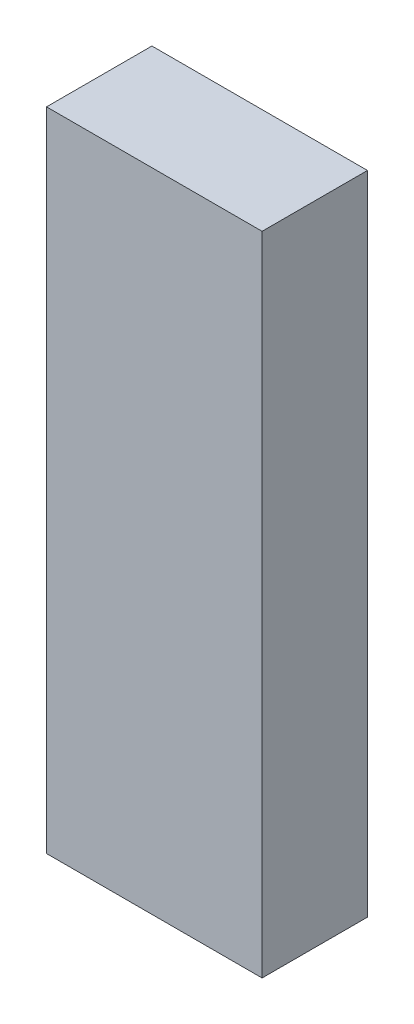
from build123d import *

# Parameters (mm, degrees)
SKETCH1_W           = 45
SKETCH1_H           = 22
BOSS_EXTRUDE1_DEPTH = 67.5


with BuildPart() as part:
    # Sketch1 → Boss-Extrude1 (new body, symmetric)
    with BuildSketch(Plane(origin=(0, 0, 0), x_dir=(1, 0, 0), z_dir=(0, 1, 0))):
        Rectangle(SKETCH1_W, SKETCH1_H)
    extrude(amount=BOSS_EXTRUDE1_DEPTH, both=True)


solid = part.part
